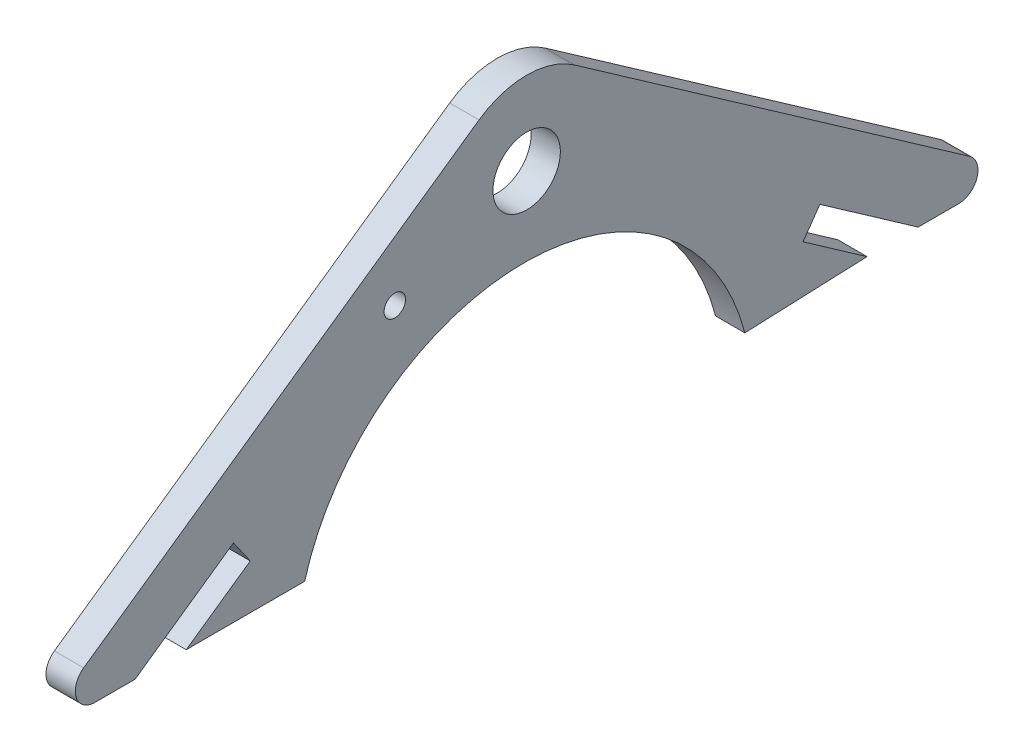
from build123d import *

# Parameters (mm, degrees)
SKETCH1_R           = 3.45
SKETCH1_R_2         = 1.1
BOSS_EXTRUDE1_DEPTH = 3


with BuildPart() as part:
    # Sketch1 → Boss-Extrude1 (new body)
    with BuildSketch(Plane(origin=(0, 0, 0), x_dir=(0, 0, -1), z_dir=(1, 0, 0))):
        with BuildLine():
            Line((-4.875399709, 6.962792376), (-45.326961199, -21.361695911))
            ThreePointArc((-45.326961199, -21.361695911), (-46.087242228, -23.601411599), (-44.179808327, -25))
            Line((-44.179808327, -25), (-40.062317158, -25))
            Line((-40.062317158, -25), (-29.999489725, -17.953932376))
            Line((-29.999489725, -17.953932376), (-28.278760416, -20.411388509))
            Line((-28.278760416, -20.411388509), (-34.831976771, -25))
            Line((-34.831976771, -25), (-22.712020043, -25))
            ThreePointArc((-22.712020043, -25), (0, -8), (22.324675322, -25.505562722))
            Line((22.324675322, -25.505562722), (34.831976771, -25))
            Line((34.831976771, -25), (28.278760416, -20.411388509))
            Line((28.278760416, -20.411388509), (29.999489725, -17.953932376))
            Line((29.999489725, -17.953932376), (40.062317158, -25))
            Line((40.062317158, -25), (44.179808327, -25))
            ThreePointArc((44.179808327, -25), (46.087242228, -23.601411599), (45.326961199, -21.361695911))
            Line((45.326961199, -21.361695911), (4.875399709, 6.962792376))
            ThreePointArc((4.875399709, 6.962792376), (0, 8.5), (-4.875399709, 6.962792376))
        make_face()
        Circle(SKETCH1_R, mode=Mode.SUBTRACT)
        with Locations((-13.491798398, -5.174347881)):
            Circle(SKETCH1_R_2, mode=Mode.SUBTRACT)
    extrude(amount=BOSS_EXTRUDE1_DEPTH)


solid = part.part
